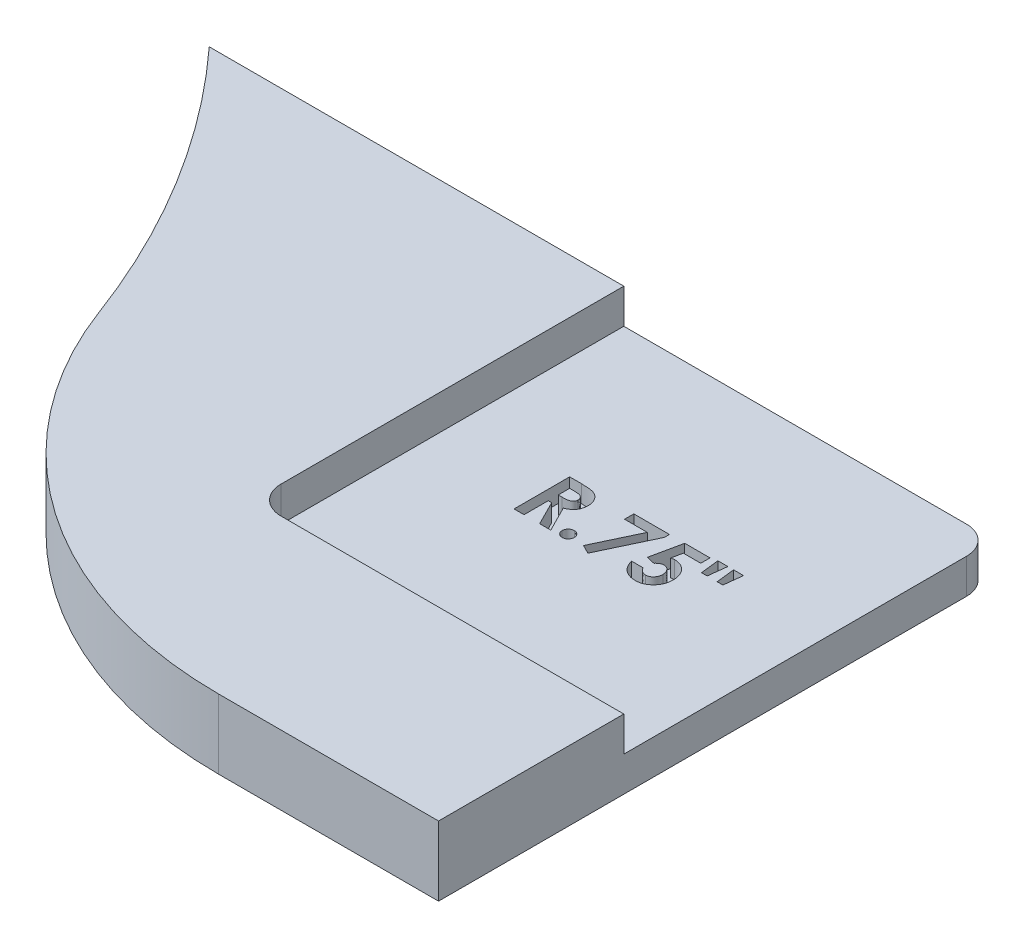
from build123d import *

# Parameters (mm, degrees)
BOSS_EXTRUDE1_DEPTH = 1.5875
FILLET1_R           = 19.05
SKETCH3_W           = 16.933333334
SKETCH3_H           = 16.933333333
CUT_EXTRUDE1_DEPTH  = 1.5875
CUT_EXTRUDE2_DEPTH  = 0.79375
FILLET2_R           = 1.27


with BuildPart() as part:
    # Sketch2 → Boss-Extrude1 (new, symmetric)
    with BuildSketch(Plane(origin=(0, 0, 0), x_dir=(1, 0, 0), z_dir=(0, 1, 0))):
        with BuildLine():
            Line((39.871809281, 1.5875), (65.271809281, 1.5875))
            Line((65.271809281, 1.5875), (65.271809281, 26.9875))
            Line((65.271809281, 26.9875), (29.393131431, 26.9875))
            ThreePointArc((29.393131431, 26.9875), (36.887640246, 15.217862157), (39.871809281, 1.5875))
        make_face()
    extrude(amount=BOSS_EXTRUDE1_DEPTH, both=True)

    # Fillet1
    fillet1_edges = [part.edges().sort_by_distance(p)[0] for p in [
        (39.871809281, 0, -1.5875),
    ]]
    fillet(fillet1_edges, radius=FILLET1_R)

    # Sketch3 → Cut-Extrude1 (cut)
    with BuildSketch(Plane(origin=(0, 1.5875, 0), x_dir=(1, 0, 0), z_dir=(0, 1, 0))):
        with Locations((56.805142614, 18.520833334)):
            Rectangle(SKETCH3_W, SKETCH3_H)
    extrude(amount=-CUT_EXTRUDE1_DEPTH, mode=Mode.SUBTRACT)

    # Sketch4 → Cut-Extrude2 (cut)
    with BuildSketch(Plane(origin=(0, 0, 0), x_dir=(1, 0, 0), z_dir=(0, 1, 0))):
        with BuildLine():
            Line((53.060270819, 19.790833333), (53.591472742, 19.790833333))
            add(Edge.make_bspline(
                [(53.591472742, 19.790833333), (53.626585028, 19.790708705), (53.694115843, 19.790469009), (53.79149159, 19.786687247), (53.880944606, 19.781424614), (53.962607332, 19.773393697), (54.036444834, 19.762745672), (54.102531112, 19.750193413), (54.160864235, 19.735887422), (54.211936163, 19.718061028), (54.258026053, 19.697953127), (54.300988238, 19.674848779), (54.341770528, 19.64900526), (54.380100337, 19.619742555), (54.416310761, 19.587587095), (54.450470112, 19.552506512), (54.482095687, 19.514203335), (54.51099166, 19.472919594), (54.537328013, 19.429490045), (54.560603826, 19.383855059), (54.579531755, 19.3359829), (54.59625661, 19.286565425), (54.608302981, 19.234896199), (54.616681056, 19.181478234), (54.622815154, 19.12612349), (54.623167836, 19.088517935), (54.623347742, 19.069334936)],
                knots=[0, 0, 0, 0, 1.749336639, 3.364467119, 4.854658419, 6.213483162, 7.451590619, 8.570285859, 9.5643256, 10.440900261, 11.26203566, 12.067320669, 12.869050712, 13.665104639, 14.467235401, 15.27997916, 16.102287765, 16.939272006, 17.78853747, 18.631303466, 19.488103222, 20.351255419, 21.228522269, 22.127379805, 23.044756219, 24, 24, 24, 24], degree=3))
            add(Edge.make_bspline(
                [(54.623347742, 19.069334936), (54.62288041, 19.049312291), (54.621964056, 19.010051534), (54.617028075, 18.952380684), (54.608006652, 18.897205248), (54.594342395, 18.844686774), (54.578637107, 18.794171608), (54.557753101, 18.746591786), (54.534183437, 18.701255329), (54.506190436, 18.658803538), (54.475469485, 18.618293474), (54.439741665, 18.581277228), (54.40132159, 18.545765316), (54.358049528, 18.513982085), (54.311832951, 18.483778467), (54.261753585, 18.456405945), (54.208138265, 18.431176438), (54.170444039, 18.417106723), (54.151168255, 18.409911859)],
                knots=[0, 0, 0, 0, 1.099860209, 2.156625411, 3.176576793, 4.16617041, 5.135385252, 6.078461593, 7.016046972, 7.938469504, 8.868247731, 9.803980173, 10.76021508, 11.73834243, 12.748633912, 13.790971185, 14.870363756, 16, 16, 16, 16], degree=3))
            Line((54.151168255, 18.409911859), (54.737322101, 17.250833333))
            Line((54.737322101, 17.250833333), (54.230543255, 17.250833333))
            Line((54.230543255, 17.250833333), (53.670847742, 18.358012821))
            Line((53.670847742, 18.358012821), (53.516168255, 18.358012821))
            Line((53.516168255, 18.358012821), (53.516168255, 17.250833333))
            Line((53.516168255, 17.250833333), (53.060270819, 17.250833333))
            Line((53.060270819, 17.250833333), (53.060270819, 19.790833333))
        make_face()
        with BuildLine():
            Line((53.516168255, 18.813910256), (53.693744377, 18.813910256))
            add(Edge.make_bspline(
                [(53.693744377, 18.813910256), (53.715454534, 18.814154771), (53.757024819, 18.814622963), (53.81680835, 18.816794634), (53.871106054, 18.822027288), (53.920151103, 18.82863855), (53.964190287, 18.836272207), (54.002830794, 18.847211702), (54.036668013, 18.858933647), (54.065300973, 18.873500984), (54.089764316, 18.890067205), (54.110886847, 18.908886845), (54.128358208, 18.930668181), (54.14273803, 18.954819292), (54.153923968, 18.981553787), (54.162088846, 19.010578183), (54.166651805, 19.042223104), (54.167176789, 19.064062409), (54.167450306, 19.075440705)],
                knots=[0, 0, 0, 0, 1.688639943, 3.233382647, 4.650958383, 5.928841754, 7.082724185, 8.122798841, 9.049171256, 9.863274652, 10.613301712, 11.341792392, 12.054588806, 12.776240173, 13.521029143, 14.301969904, 15.115324896, 16, 16, 16, 16], degree=3))
            add(Edge.make_bspline(
                [(54.167450306, 19.075440705), (54.166933197, 19.08890206), (54.165917432, 19.115344397), (54.155837887, 19.153412091), (54.139793427, 19.188646346), (54.117800868, 19.220887966), (54.0901041, 19.249153195), (54.058319872, 19.27406922), (54.021762206, 19.293770948), (53.987912558, 19.306765998), (53.95711729, 19.31454107), (53.929325532, 19.320334985), (53.89714251, 19.324441299), (53.860543926, 19.328796776), (53.819623072, 19.331621083), (53.774156904, 19.333682263), (53.724276001, 19.334525594), (53.689504274, 19.334795192), (53.671356556, 19.334935897)],
                knots=[0, 0, 0, 0, 1.020303359, 2.004196876, 2.966617323, 3.9489082, 4.950758222, 5.960522915, 7.003732012, 8.091992268, 8.70421221, 9.413913587, 10.24622431, 11.166358409, 12.212345909, 13.359657661, 14.621978493, 16, 16, 16, 16], degree=3))
            Line((53.671356556, 19.334935897), (53.516168255, 19.334935897))
            Line((53.516168255, 19.334935897), (53.516168255, 18.813910256))
        make_face(mode=Mode.SUBTRACT)
        with BuildLine():
            add(Edge.make_bspline(
                [(55.290911845, 17.771858974), (55.309315884, 17.770849925), (55.345550258, 17.768863281), (55.397903988, 17.754037168), (55.445153531, 17.727399942), (55.487400936, 17.692656297), (55.523124277, 17.650855054), (55.5489443, 17.603185847), (55.565023077, 17.551033843), (55.566798185, 17.514685471), (55.567706717, 17.496081731)],
                knots=[0, 0, 0, 0, 1.016957001, 2.002212695, 2.9757545, 3.99499976, 5.013036768, 5.994806404, 6.97370641, 8, 8, 8, 8], degree=3))
            add(Edge.make_bspline(
                [(55.567706717, 17.496081731), (55.566804136, 17.477475003), (55.565040657, 17.441120793), (55.548833037, 17.388867167), (55.52316286, 17.340806163), (55.487398069, 17.298556992), (55.445328492, 17.263158571), (55.397795353, 17.236766979), (55.345649991, 17.221099817), (55.309333438, 17.219221837), (55.290911845, 17.218269231)],
                knots=[0, 0, 0, 0, 1.023218912, 1.999186227, 2.986238111, 4.008388923, 5.030539734, 6.0011649, 6.986089706, 8, 8, 8, 8], degree=3))
            add(Edge.make_bspline(
                [(55.290911845, 17.218269231), (55.272485887, 17.219214091), (55.236160729, 17.2210768), (55.18393431, 17.236899038), (55.136050244, 17.26298237), (55.093970097, 17.29859993), (55.058045525, 17.340656555), (55.033105175, 17.389018808), (55.016746586, 17.441101093), (55.015007214, 17.477468333), (55.014116973, 17.496081731)],
                knots=[0, 0, 0, 0, 1.013427518, 1.99788335, 2.976245624, 3.997909735, 5.019573847, 6.001765691, 6.977268297, 8, 8, 8, 8], degree=3))
            add(Edge.make_bspline(
                [(55.014116973, 17.496081731), (55.015013087, 17.514692257), (55.016763934, 17.551053886), (55.032994228, 17.603032459), (55.058085496, 17.651005475), (55.093967101, 17.69261327), (55.136226107, 17.727574767), (55.183825065, 17.753906918), (55.236260411, 17.768886469), (55.27250342, 17.770857735), (55.290911845, 17.771858974)],
                knots=[0, 0, 0, 0, 1.025808215, 2.00424526, 2.981110158, 3.998665696, 5.017428914, 5.998734231, 6.983523959, 8, 8, 8, 8], degree=3))
        make_face()
        Polygon((55.99104005, 19.790833333), (57.619245178, 19.790833333), (57.619245178, 19.554234776), (56.498836524, 17.185705128), (56.095346941, 17.389230769), (57.031056075, 19.3675), (55.99104005, 19.3675), align=None)
        with BuildLine():
            Line((58.318864569, 19.790833333), (59.475399024, 19.790833333))
            Line((59.475399024, 19.790833333), (59.475399024, 19.3675))
            Line((59.475399024, 19.3675), (58.680122582, 19.3675))
            Line((58.680122582, 19.3675), (58.580903832, 18.887179487))
            add(Edge.make_bspline(
                [(58.580903832, 18.887179487), (58.594423807, 18.890944971), (58.621087975, 18.898371278), (58.661257578, 18.905818925), (58.700187521, 18.910646253), (58.725733113, 18.911290154), (58.73812739, 18.911602564)],
                knots=[0, 0, 0, 0, 1.05461699, 2.079921384, 3.068411212, 4, 4, 4, 4], degree=3))
            add(Edge.make_bspline(
                [(58.73812739, 18.911602564), (58.765135818, 18.910983682), (58.818375379, 18.909763728), (58.896258101, 18.898182388), (58.970835409, 18.879942129), (59.041879087, 18.853927756), (59.109319735, 18.820069377), (59.173239105, 18.779110231), (59.233715646, 18.730978377), (59.289675042, 18.675643681), (59.341092872, 18.614884932), (59.385797743, 18.549167915), (59.423978492, 18.479429693), (59.45434614, 18.405236773), (59.478314877, 18.327055137), (59.495635221, 18.244834683), (59.505877606, 18.158477969), (59.507258729, 18.099562957), (59.507963127, 18.069515224)],
                knots=[0, 0, 0, 0, 1.01440847, 1.999622559, 2.951875003, 3.895578053, 4.836219714, 5.782137149, 6.743708247, 7.735272588, 8.734977101, 9.730283169, 10.717124674, 11.717316708, 12.737475749, 13.78628267, 14.87096371, 16, 16, 16, 16], degree=3))
            add(Edge.make_bspline(
                [(59.507963127, 18.069515224), (59.507102341, 18.03912638), (59.50540376, 17.979160308), (59.494322072, 17.89098897), (59.474762695, 17.806540734), (59.447895933, 17.725589532), (59.412500694, 17.648730338), (59.369933074, 17.575166947), (59.319473371, 17.505445397), (59.261616767, 17.440280418), (59.198719049, 17.380718377), (59.131747826, 17.328321535), (59.061173593, 17.284230017), (58.986994645, 17.248596616), (58.909636571, 17.220404103), (58.829075893, 17.1998813), (58.744921095, 17.188112612), (58.687790922, 17.186516441), (58.65875239, 17.185705128)],
                knots=[0, 0, 0, 0, 1.06808661, 2.107647099, 3.116961351, 4.110378221, 5.100014249, 6.085620622, 7.093190682, 8.119403071, 9.144090782, 10.133780668, 11.103064255, 12.062861538, 13.020824475, 13.992378307, 14.979551724, 16, 16, 16, 16], degree=3))
            add(Edge.make_bspline(
                [(58.65875239, 17.185705128), (58.632784095, 17.186368833), (58.581569183, 17.187677798), (58.506131866, 17.195723384), (58.433401915, 17.209948055), (58.363765447, 17.230534838), (58.29648977, 17.255872468), (58.23235261, 17.287561963), (58.171001522, 17.324999911), (58.11261072, 17.36750307), (58.058128971, 17.415381231), (58.008403804, 17.467792126), (57.963134176, 17.524075143), (57.923288786, 17.584924643), (57.888992537, 17.650250725), (57.858577924, 17.719283505), (57.833683259, 17.792743905), (57.821049933, 17.843670736), (57.814629793, 17.869551282)],
                knots=[0, 0, 0, 0, 1.054957082, 2.080596141, 3.077793124, 4.061112343, 5.027190972, 5.994718051, 6.962465889, 7.943658696, 8.924948258, 9.904494768, 10.875059, 11.855380583, 12.854004648, 13.869083016, 14.917087635, 16, 16, 16, 16], degree=3))
            Line((57.814629793, 17.869551282), (58.335655434, 17.869551282))
            add(Edge.make_bspline(
                [(58.335655434, 17.869551282), (58.345179796, 17.851617118), (58.363689305, 17.816764116), (58.398898484, 17.770491519), (58.438312924, 17.731032236), (58.481577086, 17.698000741), (58.528971295, 17.673254108), (58.578564326, 17.654487406), (58.630979195, 17.643642824), (58.666676035, 17.642287144), (58.684701909, 17.641602564)],
                knots=[0, 0, 0, 0, 1.104910296, 2.147267069, 3.153527244, 4.136738762, 5.099945312, 6.05603338, 7.018353, 8, 8, 8, 8], degree=3))
            add(Edge.make_bspline(
                [(58.684701909, 17.641602564), (58.697265701, 17.642075272), (58.721985173, 17.643005333), (58.758405407, 17.647925589), (58.79317012, 17.657244443), (58.82653778, 17.670148889), (58.85859802, 17.686242191), (58.888891247, 17.706558936), (58.917944507, 17.729944262), (58.945315493, 17.756779004), (58.970105717, 17.786693499), (58.991844031, 17.818838663), (59.011281082, 17.852500223), (59.025678403, 17.8890116), (59.037468591, 17.927282549), (59.046151363, 17.96760176), (59.051340298, 18.010016324), (59.051820655, 18.038971558), (59.052065691, 18.053741987)],
                knots=[0, 0, 0, 0, 0.978869489, 1.925942215, 2.855067702, 3.774946051, 4.70828698, 5.642468714, 6.60995405, 7.609372294, 8.622401667, 9.629904756, 10.629323, 11.642352373, 12.678539694, 13.745912462, 14.850161547, 16, 16, 16, 16], degree=3))
            add(Edge.make_bspline(
                [(59.052065691, 18.053741987), (59.051781298, 18.068169561), (59.051227721, 18.096253185), (59.046648421, 18.137490004), (59.038456142, 18.176616282), (59.027294092, 18.213931698), (59.013005334, 18.249209654), (58.995543518, 18.282660141), (58.974834043, 18.31411408), (58.950765726, 18.3429311), (58.92509952, 18.369362889), (58.897525767, 18.392479922), (58.868292893, 18.411665454), (58.838309273, 18.428414982), (58.806378068, 18.440604923), (58.773217284, 18.448999686), (58.738861792, 18.455159425), (58.715428657, 18.455521332), (58.703528031, 18.455705128)],
                knots=[0, 0, 0, 0, 1.166249705, 2.270133367, 3.348514167, 4.393962215, 5.415026464, 6.420877785, 7.440098956, 8.453121383, 9.451844239, 10.415694839, 11.355045125, 12.27538808, 13.187007209, 14.108269027, 15.039275622, 16, 16, 16, 16], degree=3))
            add(Edge.make_bspline(
                [(58.703528031, 18.455705128), (58.690601184, 18.455214626), (58.664693011, 18.454231555), (58.626199949, 18.446232567), (58.588171007, 18.433287203), (58.550394704, 18.415427023), (58.513246036, 18.392053682), (58.475744631, 18.364639432), (58.439145741, 18.33119237), (58.415875149, 18.306280922), (58.403836524, 18.293393429)],
                knots=[0, 0, 0, 0, 0.88288272, 1.769486374, 2.674910571, 3.623812639, 4.617874466, 5.670434592, 6.794841017, 8, 8, 8, 8], degree=3))
            Line((58.403836524, 18.293393429), (58.020190691, 18.381418269))
            Line((58.020190691, 18.381418269), (58.318864569, 19.790833333))
        make_face()
        Polygon((60.843091332, 19.009294872), (60.582578511, 19.009294872), (60.484886204, 19.855961538), (60.94078364, 19.855961538), align=None)
        Polygon((60.126681075, 19.009294872), (59.866168255, 19.009294872), (59.768475947, 19.855961538), (60.224373383, 19.855961538), align=None)
    extrude(amount=-CUT_EXTRUDE2_DEPTH, mode=Mode.SUBTRACT)

    # Fillet2
    fillet2_edges = [part.edges().sort_by_distance(p)[0] for p in [
        (65.271809281, -0.79375, -26.9875),
        (48.338475947, 0.79375, -10.054166667),
    ]]
    fillet(fillet2_edges, radius=FILLET2_R)


solid = part.part
